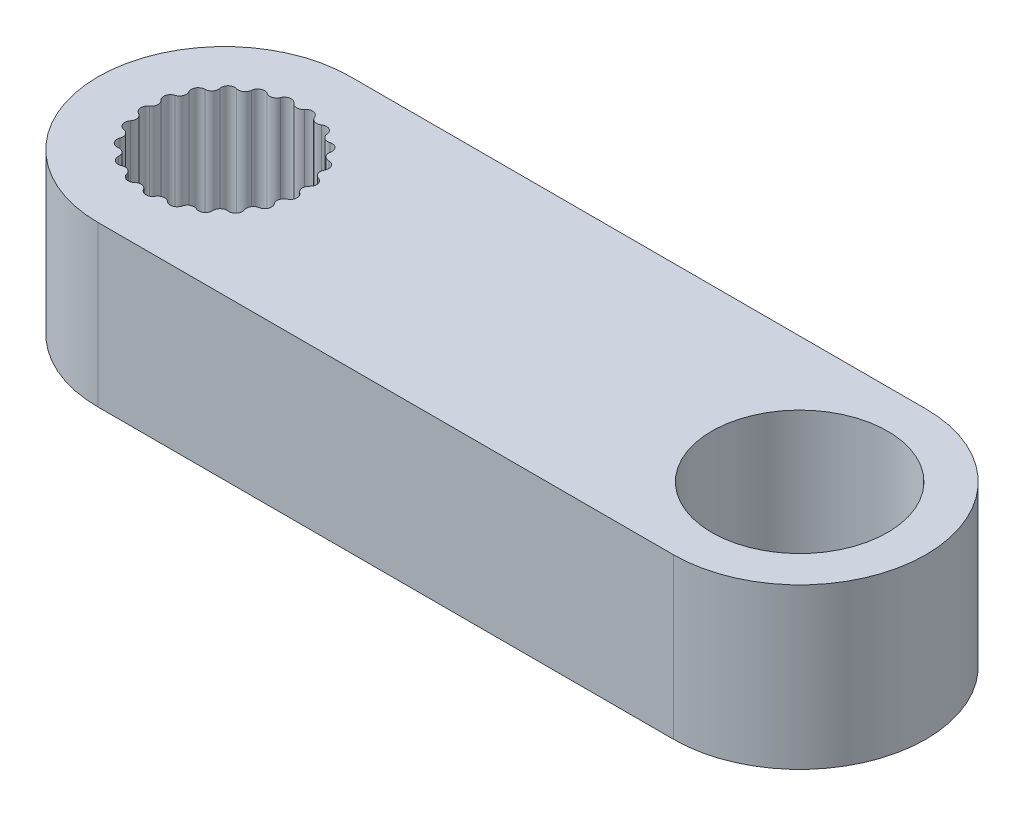
from build123d import *

# Parameters (mm, degrees)
SKETCH1_R           = 3.95
BOSS_EXTRUDE1_DEPTH = 5
BOSS_EXTRUDE2_DEPTH = 5
SKETCH3_R           = 2.75
CUT_EXTRUDE1_DEPTH  = 5


with BuildPart() as part:
    # Sketch1 → Boss-Extrude1 (new body)
    with BuildSketch(Plane(origin=(0, 0, 0), x_dir=(1, 0, 0), z_dir=(0, 1, 0))):
        Circle(SKETCH1_R)
        with BuildLine():
            ThreePointArc((-0.166646614, 2.345141313), (-0.092401566, 2.286261662), (0, 2.2652595))
            ThreePointArc((0, 2.2652595), (0.092401566, 2.286261662), (0.166646614, 2.345141313))
            ThreePointArc((0.166646614, 2.345141313), (0.365153552, 2.422635524), (0.531999564, 2.290073216))
            ThreePointArc((0.531999564, 2.290073216), (0.585591031, 2.211925311), (0.667696959, 2.164620376))
            ThreePointArc((0.667696959, 2.164620376), (0.762183879, 2.157453631), (0.850485509, 2.191833312))
            ThreePointArc((0.850485509, 2.191833312), (1.063015161, 2.207373726), (1.183375246, 2.031522064))
            ThreePointArc((1.183375246, 2.031522064), (1.211551295, 1.941049689), (1.276066113, 1.871645232))
            ThreePointArc((1.276066113, 1.871645232), (1.364242809, 1.836946378), (1.458755034, 1.843771303))
            ThreePointArc((1.458755034, 1.843771303), (1.666423208, 1.795977086), (1.729602845, 1.592461261))
            ThreePointArc((1.729602845, 1.592461261), (1.72985991, 1.497703284), (1.771051193, 1.412366197))
            ThreePointArc((1.771051193, 1.412366197), (1.845082779, 1.353218377), (1.937407773, 1.331882123))
            ThreePointArc((1.937407773, 1.331882123), (2.121762239, 1.225), (2.12214764, 1.011903287))
            ThreePointArc((2.12214764, 1.011903287), (2.094462881, 0.92127937), (2.108670602, 0.827592226))
            ThreePointArc((2.108670602, 0.827592226), (2.161979047, 0.749250985), (2.243913329, 0.701649371))
            ThreePointArc((2.243913329, 0.701649371), (2.388573385, 0.545176288), (2.326130305, 0.341433266))
            ThreePointArc((2.326130305, 0.341433266), (2.272963633, 0.262995741), (2.258925375, 0.169283054))
            ThreePointArc((2.258925375, 0.169283054), (2.286773988, 0.078709355), (2.351037339, 0.009071994))
            ThreePointArc((2.351037339, 0.009071994), (2.443149303, -0.183088729), (2.323426084, -0.3593746))
            ThreePointArc((2.323426084, -0.3593746), (2.249501592, -0.418656214), (2.208464714, -0.504067659))
            ThreePointArc((2.208464714, -0.504067659), (2.208379026, -0.598825947), (2.249261363, -0.68431147))
            ThreePointArc((2.249261363, -0.68431147), (2.280640684, -0.89508551), (2.114275259, -1.028250455))
            ThreePointArc((2.114275259, -1.028250455), (2.026161462, -1.063108727), (1.961772273, -1.13262975))
            ThreePointArc((1.961772273, -1.13262975), (1.933759896, -1.223152935), (1.947628645, -1.316890857))
            ThreePointArc((1.947628645, -1.316890857), (1.915487132, -1.527550015), (1.717261799, -1.605761745))
            ThreePointArc((1.717261799, -1.605761745), (1.622787995, -1.613099364), (1.540767756, -1.660552716))
            ThreePointArc((1.540767756, -1.660552716), (1.487317713, -1.738797417), (1.472940575, -1.832458712))
            ThreePointArc((1.472940575, -1.832458712), (1.380134142, -2.024284997), (1.167662092, -2.040594058))
            ThreePointArc((1.167662092, -2.040594058), (1.075222693, -2.019759044), (0.982859262, -2.040928287))
            ThreePointArc((0.982859262, -2.040928287), (0.908720824, -2.099942118), (0.86737527, -2.185204569))
            ThreePointArc((0.86737527, -2.185204569), (0.722150177, -2.341153374), (0.514310485, -2.294110633))
            ThreePointArc((0.514310485, -2.294110633), (0.432119136, -2.246954269), (0.337619409, -2.239958423))
            ThreePointArc((0.337619409, -2.239958423), (0.249380102, -2.274497747), (0.184739867, -2.343785411))
            ThreePointArc((0.184739867, -2.343785411), (0, -2.45), (-0.184739867, -2.343785411))
            ThreePointArc((-0.184739867, -2.343785411), (-0.249380102, -2.274497747), (-0.337619409, -2.239958423))
            ThreePointArc((-0.337619409, -2.239958423), (-0.432119136, -2.246954269), (-0.514310485, -2.294110633))
            ThreePointArc((-0.514310485, -2.294110633), (-0.722150177, -2.341153374), (-0.86737527, -2.185204569))
            ThreePointArc((-0.86737527, -2.185204569), (-0.908720824, -2.099942118), (-0.982859262, -2.040928287))
            ThreePointArc((-0.982859262, -2.040928287), (-1.075222693, -2.019759044), (-1.167662092, -2.040594058))
            ThreePointArc((-1.167662092, -2.040594058), (-1.380134142, -2.024284997), (-1.472940575, -1.832458712))
            ThreePointArc((-1.472940575, -1.832458712), (-1.487317713, -1.738797417), (-1.540767756, -1.660552716))
            ThreePointArc((-1.540767756, -1.660552716), (-1.622787995, -1.613099364), (-1.717261799, -1.605761745))
            ThreePointArc((-1.717261799, -1.605761745), (-1.915487132, -1.527550015), (-1.947628645, -1.316890857))
            ThreePointArc((-1.947628645, -1.316890857), (-1.933759896, -1.223152935), (-1.961772273, -1.13262975))
            ThreePointArc((-1.961772273, -1.13262975), (-2.026161462, -1.063108727), (-2.114275259, -1.028250455))
            ThreePointArc((-2.114275259, -1.028250455), (-2.280640684, -0.89508551), (-2.249261363, -0.68431147))
            ThreePointArc((-2.249261363, -0.68431147), (-2.208379026, -0.598825947), (-2.208464714, -0.504067659))
            ThreePointArc((-2.208464714, -0.504067659), (-2.249501592, -0.418656214), (-2.323426084, -0.3593746))
            ThreePointArc((-2.323426084, -0.3593746), (-2.443149303, -0.183088729), (-2.351037339, 0.009071994))
            ThreePointArc((-2.351037339, 0.009071994), (-2.286773988, 0.078709355), (-2.258925375, 0.169283054))
            ThreePointArc((-2.258925375, 0.169283054), (-2.272963633, 0.262995741), (-2.326130305, 0.341433266))
            ThreePointArc((-2.326130305, 0.341433266), (-2.388573385, 0.545176288), (-2.243913329, 0.701649371))
            ThreePointArc((-2.243913329, 0.701649371), (-2.161979047, 0.749250985), (-2.108670602, 0.827592226))
            ThreePointArc((-2.108670602, 0.827592226), (-2.094462881, 0.92127937), (-2.12214764, 1.011903287))
            ThreePointArc((-2.12214764, 1.011903287), (-2.121762239, 1.225), (-1.937407773, 1.331882123))
            ThreePointArc((-1.937407773, 1.331882123), (-1.845082779, 1.353218377), (-1.771051193, 1.412366197))
            ThreePointArc((-1.771051193, 1.412366197), (-1.72985991, 1.497703284), (-1.729602845, 1.592461261))
            ThreePointArc((-1.729602845, 1.592461261), (-1.666423208, 1.795977086), (-1.458755034, 1.843771303))
            ThreePointArc((-1.458755034, 1.843771303), (-1.364242809, 1.836946378), (-1.276066113, 1.871645232))
            ThreePointArc((-1.276066113, 1.871645232), (-1.211551295, 1.941049689), (-1.183375246, 2.031522064))
            ThreePointArc((-1.183375246, 2.031522064), (-1.063015161, 2.207373726), (-0.850485509, 2.191833312))
            ThreePointArc((-0.850485509, 2.191833312), (-0.762183879, 2.157453631), (-0.667696959, 2.164620376))
            ThreePointArc((-0.667696959, 2.164620376), (-0.585591031, 2.211925311), (-0.531999564, 2.290073216))
            ThreePointArc((-0.531999564, 2.290073216), (-0.365153552, 2.422635524), (-0.166646614, 2.345141313))
        make_face(mode=Mode.SUBTRACT)
    extrude(amount=BOSS_EXTRUDE1_DEPTH)

    # Sketch2 → Boss-Extrude2 (add)
    with BuildSketch(Plane.XZ):
        with BuildLine():
            Line((0, 3.95), (18, 3.95))
            ThreePointArc((18, 3.95), (21.95, 0), (18, -3.95))
            Line((18, -3.95), (0, -3.95))
            ThreePointArc((0, -3.95), (3.95, 0), (0, 3.95))
        make_face()
    extrude(amount=-BOSS_EXTRUDE2_DEPTH)

    # Sketch3 → Cut-Extrude1 (cut)
    with BuildSketch(Plane(origin=(0, 5, 0), x_dir=(1, 0, 0), z_dir=(0, 1, 0))):
        with Locations((18, 0)):
            Circle(SKETCH3_R)
    extrude(amount=-CUT_EXTRUDE1_DEPTH, mode=Mode.SUBTRACT)


solid = part.part
